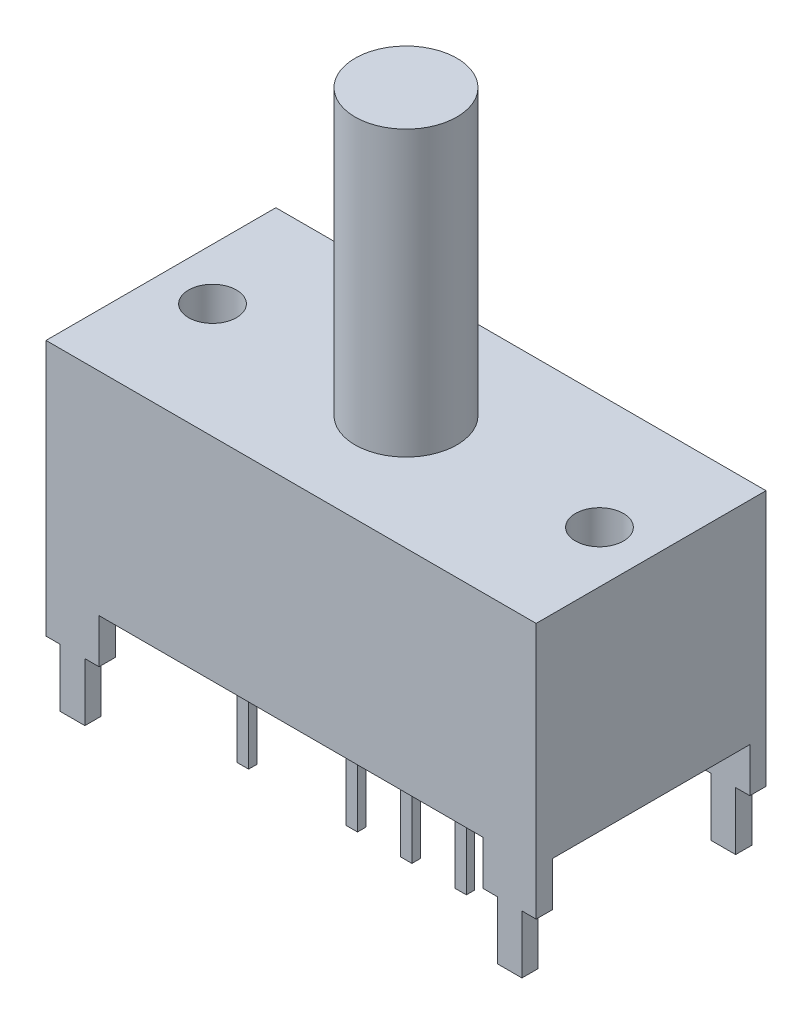
from build123d import *

# Parameters (mm, degrees)
SKETCH1_W               = 23.1
SKETCH1_H               = 10.8331
BOSS_EXTRUDE1_DEPTH     = 9.9822
SKETCH2_W               = 2.5019
SKETCH2_H               = 0.762
BOSS_EXTRUDE2_DEPTH     = 4.826
SKETCH3_W               = 0.5461
SKETCH3_H               = 0.3937
BOSS_EXTRUDE3_DEPTH     = 5.461
LPATTERN1_COUNT         = 5
LPATTERN1_PITCH         = 2.5654
LPATTERN1_COUNT_DIR2    = 2
LPATTERN1_PITCH_DIR2    = 5.08
SKETCH4_R               = 2.4003
BOSS_EXTRUDE4_DEPTH     = 13.3858
SKETCH5_R               = 1.1303
CUT_EXTRUDE1_DEPTH      = 2.54
SKETCH6_W               = 0.669118354
SKETCH6_H               = 2.7382
CUT_EXTRUDE2_DEPTH      = 1
CUT_EXTRUDE2_DEPTH_BACK = 11.8331


with BuildPart() as part:
    # Sketch1 → Boss-Extrude1 (new body)
    with BuildSketch(Plane(origin=(0, 0, 0), x_dir=(1, 0, 0), z_dir=(0, 1, 0))):
        Rectangle(SKETCH1_W, SKETCH1_H)
    extrude(amount=BOSS_EXTRUDE1_DEPTH)

    # Sketch2 → Boss-Extrude2 (add)
    with BuildSketch(Plane.XZ):
        with Locations((10.29905, -5.03555)):
            Rectangle(SKETCH2_W, SKETCH2_H)
        with Locations((10.29905, 5.03555)):
            Rectangle(SKETCH2_W, SKETCH2_H)
        with Locations((-10.29905, 5.03555)):
            Rectangle(SKETCH2_W, SKETCH2_H)
        with Locations((-10.29905, -5.03555)):
            Rectangle(SKETCH2_W, SKETCH2_H)
    extrude(amount=BOSS_EXTRUDE2_DEPTH)

    # Sketch3 → Boss-Extrude3 (add)
    with BuildSketch(Plane.XZ):
        with Locations((5.26985, -2.5781)):
            Rectangle(SKETCH3_W, SKETCH3_H)
    boss_extrude3 = extrude(amount=BOSS_EXTRUDE3_DEPTH)

    # LPattern1: Boss-Extrude3 5 × 2, 2 skipped
    with Locations(*[(-i * LPATTERN1_PITCH, 0, j * LPATTERN1_PITCH_DIR2) for i in range(LPATTERN1_COUNT) for j in range(LPATTERN1_COUNT_DIR2) if (i, j) not in ((0, 0), (3, 0), (3, 1))]):
        add(boss_extrude3)

    # Sketch4 → Boss-Extrude4 (add)
    with BuildSketch(Plane(origin=(0, 9.9822, 0), x_dir=(1, 0, 0), z_dir=(0, 1, 0))):
        Circle(SKETCH4_R)
    extrude(amount=BOSS_EXTRUDE4_DEPTH)

    # Sketch5 → Cut-Extrude1 (cut)
    with BuildSketch(Plane(origin=(0, 9.9822, 0), x_dir=(1, 0, 0), z_dir=(0, 1, 0))):
        with Locations((9.1186, 0)):
            Circle(SKETCH5_R)
        with Locations((-9.1186, 0)):
            Circle(SKETCH5_R)
    extrude(amount=-CUT_EXTRUDE1_DEPTH, mode=Mode.SUBTRACT)

    # Sketch6 → Cut-Extrude2 (cut, two sides)
    with BuildSketch(Plane(origin=(0, 0, -5.41655), x_dir=(-1, 0, 0), z_dir=(0, 0, -1))) as cut_extrude2_sk:
        with Locations((-11.215440823, -3.4569)):
            Rectangle(SKETCH6_W, SKETCH6_H)
        with Locations((-9.382659177, -3.4569)):
            Rectangle(SKETCH6_W, SKETCH6_H)
        with Locations((9.382659177, -3.4569)):
            Rectangle(SKETCH6_W, SKETCH6_H)
        with Locations((11.215440823, -3.4569)):
            Rectangle(SKETCH6_W, SKETCH6_H)
    extrude(amount=CUT_EXTRUDE2_DEPTH, mode=Mode.SUBTRACT)
    extrude(cut_extrude2_sk.sketch, amount=-CUT_EXTRUDE2_DEPTH_BACK, mode=Mode.SUBTRACT)


solid = part.part
